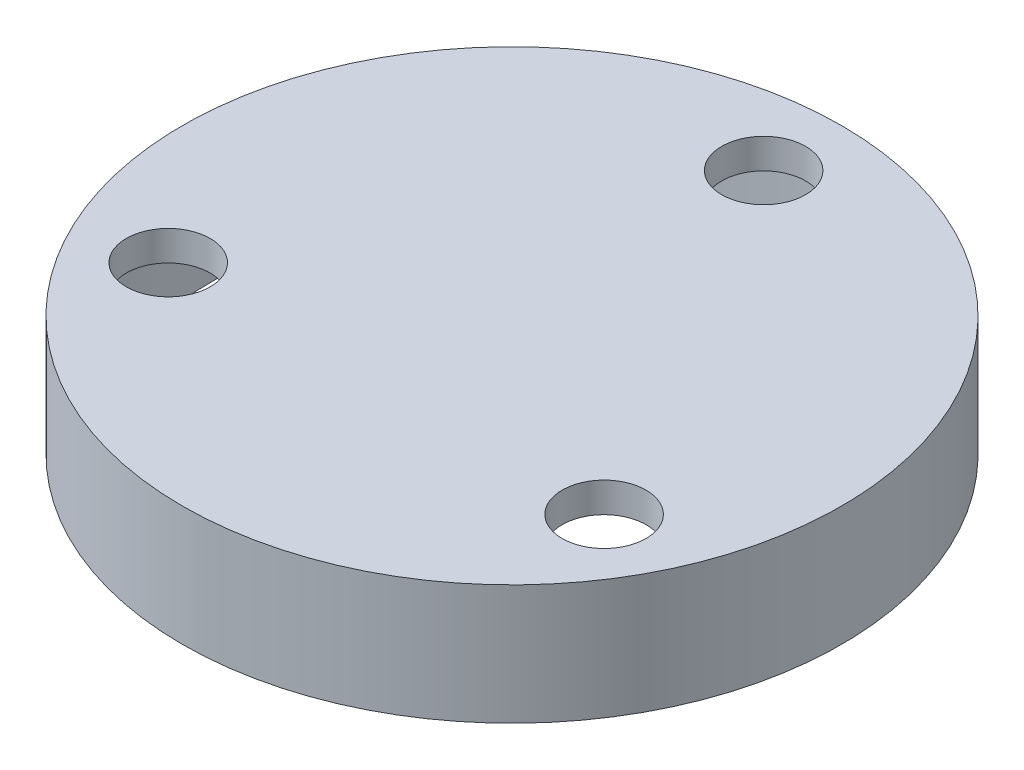
from build123d import *

# Parameters (mm, degrees)
SKETCH1_R           = 55
SKETCH1_R_2         = 7
BOSS_EXTRUDE1_DEPTH = 20
SKETCH2_R           = 50
SKETCH2_R_2         = 7
CUT_EXTRUDE1_DEPTH  = 15


with BuildPart() as part:
    # Sketch1 → Boss-Extrude1 (new body)
    with BuildSketch(Plane(origin=(0, 0, 0), x_dir=(1, 0, 0), z_dir=(0, 1, 0))):
        Circle(SKETCH1_R)
        with Locations((0, 42)):
            Circle(SKETCH1_R_2, mode=Mode.SUBTRACT)
        with Locations((36.373066959, -21)):
            Circle(SKETCH1_R_2, mode=Mode.SUBTRACT)
        with Locations((-36.373066959, -21)):
            Circle(SKETCH1_R_2, mode=Mode.SUBTRACT)
    extrude(amount=BOSS_EXTRUDE1_DEPTH)

    # Sketch2 → Cut-Extrude1 (cut)
    with BuildSketch(Plane.XZ):
        Circle(SKETCH2_R)
        with Locations((36.373066959, 21)):
            Circle(SKETCH2_R_2, mode=Mode.SUBTRACT)
        with Locations((-36.373066959, 21)):
            Circle(SKETCH2_R_2, mode=Mode.SUBTRACT)
        with Locations((0, -42)):
            Circle(SKETCH2_R_2, mode=Mode.SUBTRACT)
    extrude(amount=-CUT_EXTRUDE1_DEPTH, mode=Mode.SUBTRACT)


solid = part.part
